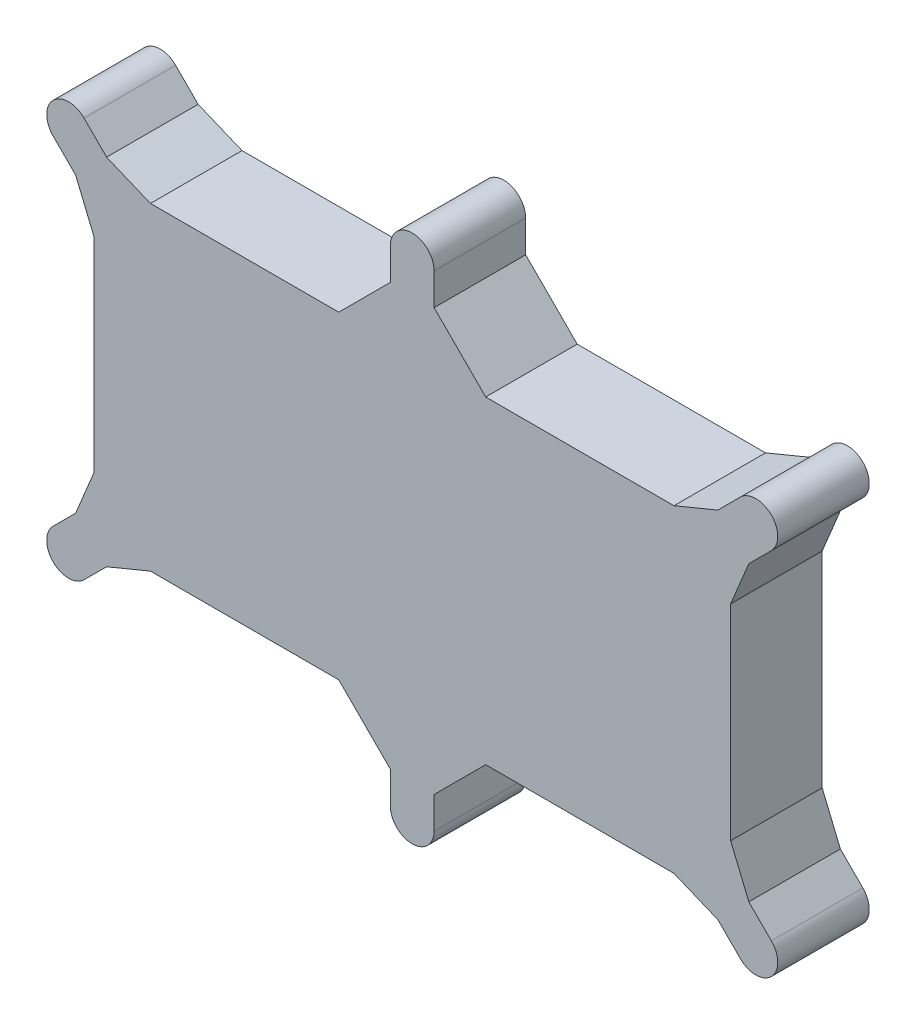
from build123d import *

# Parameters (mm, degrees)
EXTRUDE_3_DEPTH = 46


with BuildPart() as part:
    # Эскиз3 → Бобышка-Вытянуть3 (new body)
    with BuildSketch(Plane.XY):
        with BuildLine():
            Line((11, 121.91), (11, 105.91))
            Line((11, 105.91), (36.91, 80))
            Line((36.91, 80), (131.533650814, 80))
            Line((131.533650814, 80), (153.572399359, 89.128748545))
            Line((153.572399359, 89.128748545), (164.886107858, 100.442457044))
            ThreePointArc((164.886107858, 100.442457044), (180.442457044, 100.442457044), (180.442457044, 84.886107858))
            Line((180.442457044, 84.886107858), (169.128748545, 73.572399359))
            Line((169.128748545, 73.572399359), (160, 51.533650814))
            Line((160, 51.533650814), (160, -51.533650814))
            Line((160, -51.533650814), (169.128748545, -73.572399359))
            Line((169.128748545, -73.572399359), (180.442457044, -84.886107858))
            ThreePointArc((180.442457044, -84.886107858), (180.442457044, -100.442457044), (164.886107858, -100.442457044))
            Line((164.886107858, -100.442457044), (153.572399359, -89.128748545))
            Line((153.572399359, -89.128748545), (131.533650814, -80))
            Line((131.533650814, -80), (36.91, -80))
            Line((36.91, -80), (11, -105.91))
            Line((11, -105.91), (11, -121.91))
            ThreePointArc((11, -121.91), (0, -132.91), (-11, -121.91))
            Line((-11, -121.91), (-11, -105.91))
            Line((-11, -105.91), (-36.91, -80))
            Line((-36.91, -80), (-131.533650814, -80))
            Line((-131.533650814, -80), (-153.572399359, -89.128748545))
            Line((-153.572399359, -89.128748545), (-164.886107858, -100.442457044))
            ThreePointArc((-164.886107858, -100.442457044), (-180.442457044, -100.442457044), (-180.442457044, -84.886107858))
            Line((-180.442457044, -84.886107858), (-169.128748545, -73.572399359))
            Line((-169.128748545, -73.572399359), (-160, -51.533650814))
            Line((-160, -51.533650814), (-160, 51.533650814))
            Line((-160, 51.533650814), (-169.128748545, 73.572399359))
            Line((-169.128748545, 73.572399359), (-180.442457044, 84.886107858))
            ThreePointArc((-180.442457044, 84.886107858), (-180.442457044, 100.442457044), (-164.886107858, 100.442457044))
            Line((-164.886107858, 100.442457044), (-153.572399359, 89.128748545))
            Line((-153.572399359, 89.128748545), (-131.533650814, 80))
            Line((-131.533650814, 80), (-36.91, 80))
            Line((-36.91, 80), (-11, 105.91))
            Line((-11, 105.91), (-11, 121.91))
            ThreePointArc((-11, 121.91), (0, 132.91), (11, 121.91))
        make_face()
    extrude(amount=EXTRUDE_3_DEPTH)


solid = part.part
